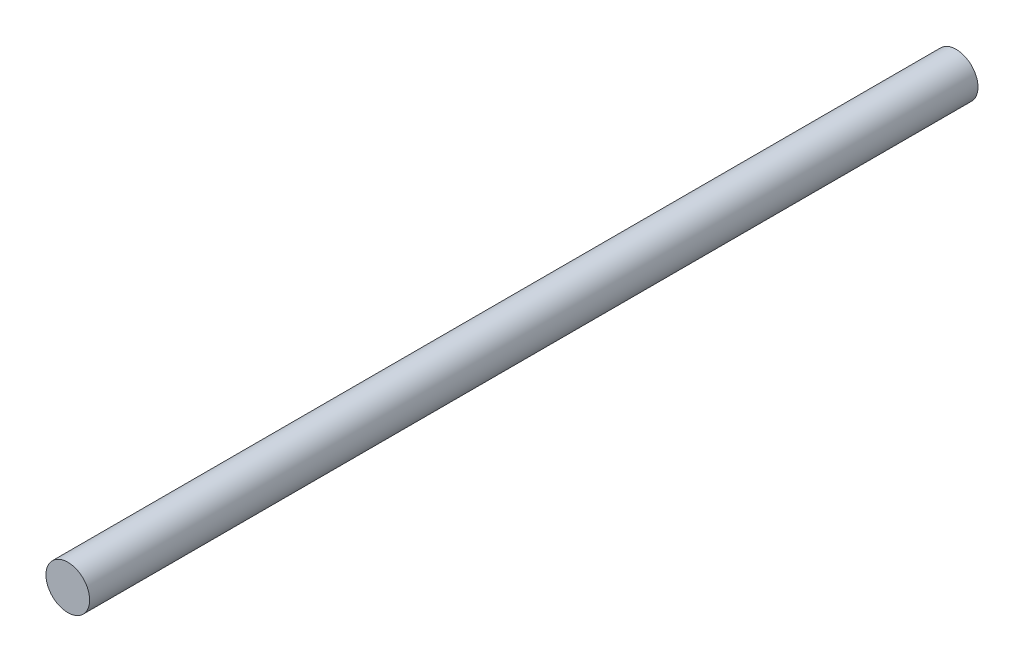
from build123d import *

# Parameters (mm, degrees)
SKETCH1_R           = 3
BOSS_EXTRUDE1_DEPTH = 122


with BuildPart() as part:
    # Sketch1 → Boss-Extrude1 (new body)
    with BuildSketch(Plane.XY):
        Circle(SKETCH1_R)
    extrude(amount=BOSS_EXTRUDE1_DEPTH)


solid = part.part
